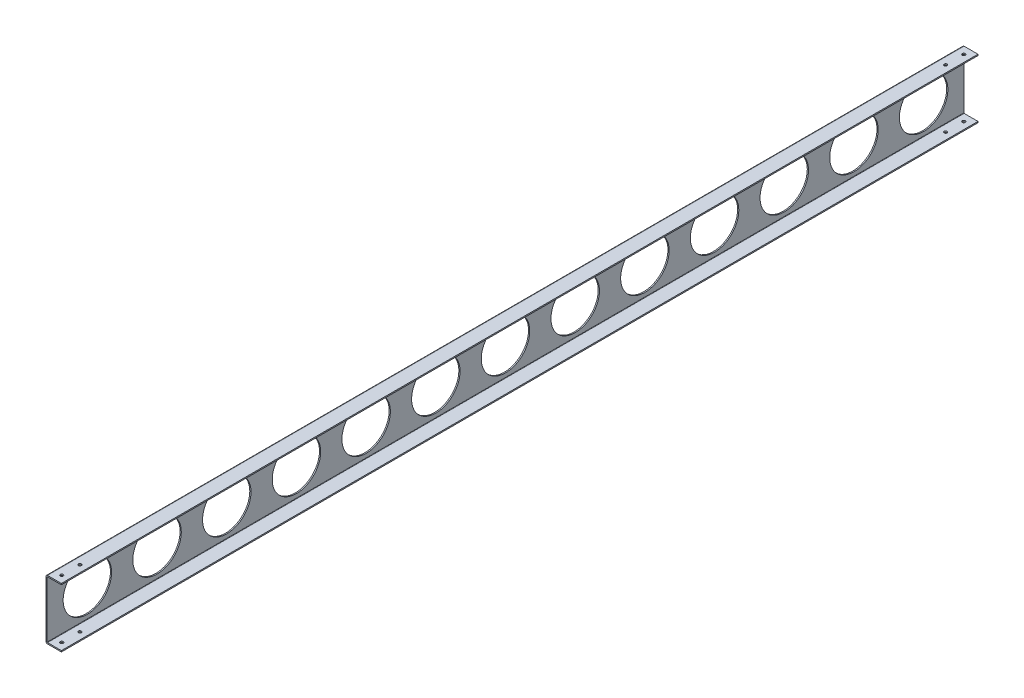
from build123d import *

# Parameters (mm, degrees)
EXTRUDE_THIN1_DEPTH    = 756.30962295
SKETCH2_R              = 40
EXTRUDE1_DEPTH         = 3
LPATTERN1_COUNT        = 7
LPATTERN1_PITCH        = 115
LPATTERN2_COUNT        = 7
LPATTERN2_PITCH        = 115
F_10_CLEARANCE_HOLE1_D = 4.9784


with BuildPart() as part:
    # Sketch1 → Extrude-Thin1 (new body, symmetric)
    with BuildSketch(Plane.XY):
        with BuildLine():
            Line((25.4, 49), (2.54, 49))
            ThreePointArc((2.54, 49), (0.743948776, 48.256051224), (0, 46.46))
            Line((0, 46.46), (0, -46.46))
            ThreePointArc((0, -46.46), (0.743948776, -48.256051224), (2.54, -49))
            Line((2.54, -49), (25.4, -49))
            Line((25.4, -49), (25.4, -47))
            Line((25.4, -47), (2.54, -47))
            ThreePointArc((2.54, -47), (2.158162338, -46.841837662), (2, -46.46))
            Line((2, -46.46), (2, 46.46))
            ThreePointArc((2, 46.46), (2.158162338, 46.841837662), (2.54, 47))
            Line((2.54, 47), (25.4, 47))
            Line((25.4, 47), (25.4, 49))
        make_face()
    extrude(amount=EXTRUDE_THIN1_DEPTH, both=True)

    # Sketch2 → Extrude1 (cut, through all)
    with BuildSketch(Plane(origin=(2, 0, 0), x_dir=(0, 0, -1), z_dir=(1, 0, 0))):
        Circle(SKETCH2_R)
    extrude1 = extrude(amount=-EXTRUDE1_DEPTH, mode=Mode.SUBTRACT)

    # LPattern1: Extrude1 ×7
    with Locations(*[(0, 0, i * LPATTERN1_PITCH) for i in range(1, LPATTERN1_COUNT)]):
        add(extrude1, mode=Mode.SUBTRACT)

    # LPattern2: Extrude1 ×7
    with Locations(*[(0, 0, -i * LPATTERN2_PITCH) for i in range(1, LPATTERN2_COUNT)]):
        add(extrude1, mode=Mode.SUBTRACT)

    # #10 Clearance Hole1 (through all)
    with Locations(Plane.XZ.offset(49)):
        with Locations((13.97, 744.30962295), (13.97, 714.30962295)):
            f_10_clearance_hole1 = Hole(F_10_CLEARANCE_HOLE1_D / 2)

    # Mirror1: #10 Clearance Hole1 across plane
    add(f_10_clearance_hole1.mirror(Plane.XY), mode=Mode.SUBTRACT)


solid = part.part
